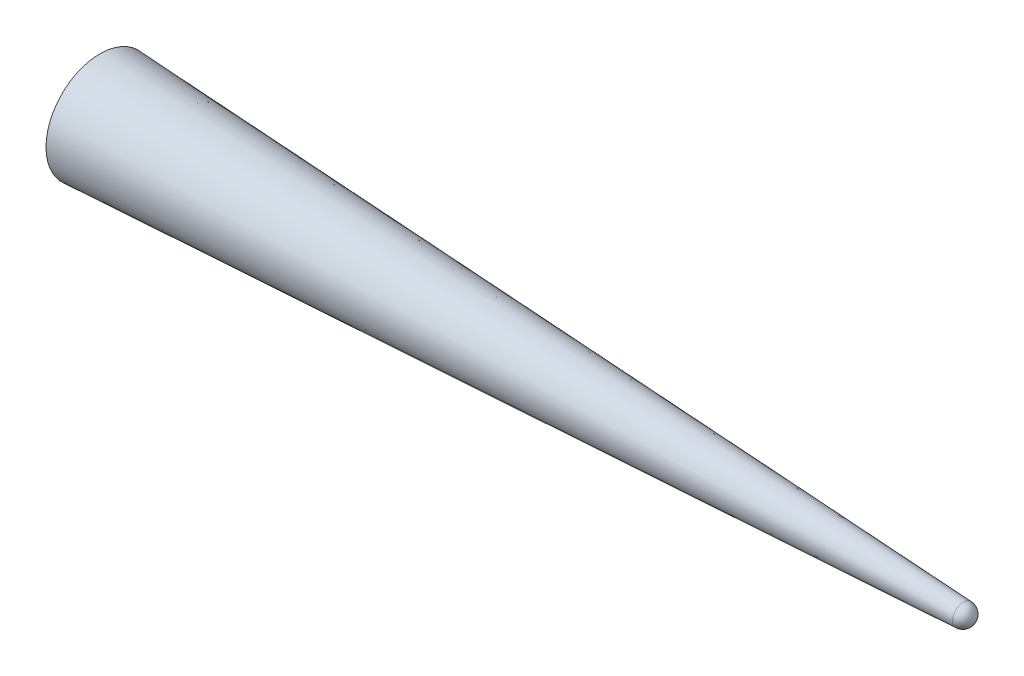
from build123d import *


with BuildPart() as part:
    # Sketch1 → Revolve2 (revolve)
    with BuildSketch(Plane(origin=(0, 0, 0), x_dir=(1, 0, 0), z_dir=(0, 1, 0))):
        with BuildLine():
            Line((0, 0), (0, 50))
            Line((0, 50), (800.249532224, 9.987523389))
            ThreePointArc((800.249532224, 9.987523389), (806.995629183, 6.892250659), (809.750156055, 0))
            Line((809.750156055, 0), (0, 0))
        make_face()
    revolve(axis=Axis((0, 0, 0), (1, 0, 0)))


solid = part.part
